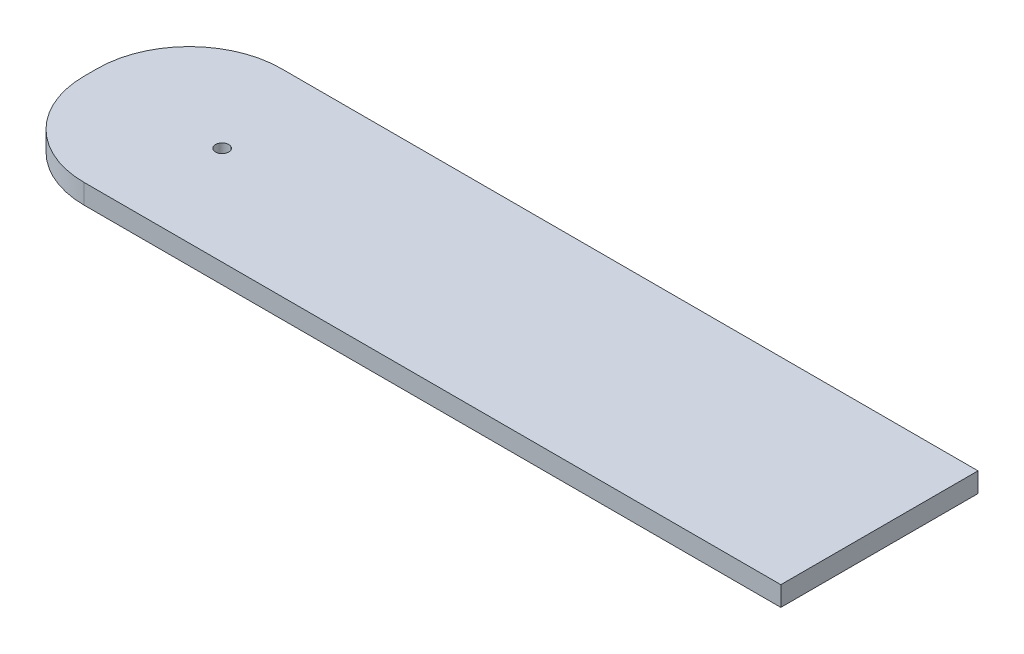
from build123d import *

# Parameters (mm, degrees)
SKETCH1_W           = 120
SKETCH1_H           = 30
BOSS_EXTRUDE1_DEPTH = 3
SKETCH3_R           = 1
CUT_EXTRUDE1_DEPTH  = 4
FILLET1_R           = 14


with BuildPart() as part:
    # Sketch1 → Boss-Extrude1 (new body)
    with BuildSketch(Plane(origin=(0, 0, 0), x_dir=(1, 0, 0), z_dir=(0, 1, 0))):
        with Locations((60, 15)):
            Rectangle(SKETCH1_W, SKETCH1_H)
    extrude(amount=BOSS_EXTRUDE1_DEPTH)

    # Sketch3 → Cut-Extrude1 (cut, through all)
    with BuildSketch(Plane(origin=(0, 3, 0), x_dir=(1, 0, 0), z_dir=(0, 1, 0))):
        with Locations((20, 15)):
            Circle(SKETCH3_R)
    extrude(amount=-CUT_EXTRUDE1_DEPTH, mode=Mode.SUBTRACT)

    # Fillet1
    fillet1_edges = [part.edges().sort_by_distance(p)[0] for p in [
        (0, 1.5, -30),
        (0, 1.5, 0),
    ]]
    fillet(fillet1_edges, radius=FILLET1_R)


solid = part.part
